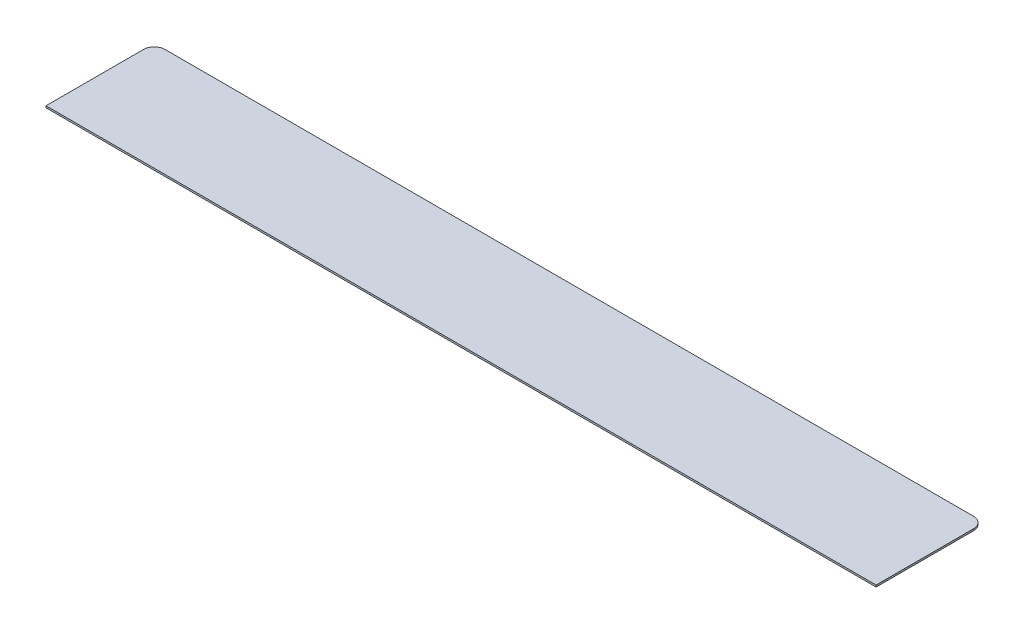
from build123d import *

# Parameters (mm, degrees)
SKETCH1_W           = 230
SKETCH1_H           = 30
BOSS_EXTRUDE1_DEPTH = 0.5
FILLET1_R           = 3


with BuildPart() as part:
    # Sketch1 → Boss-Extrude1 (new body)
    with BuildSketch(Plane(origin=(0, 0, 0), x_dir=(1, 0, 0), z_dir=(0, 1, 0))):
        Rectangle(SKETCH1_W, SKETCH1_H)
    extrude(amount=BOSS_EXTRUDE1_DEPTH)

    # Fillet1
    fillet1_edges = [part.edges().sort_by_distance(p)[0] for p in [
        (-115, 0.25, -15),
        (115, 0.25, -15),
    ]]
    fillet(fillet1_edges, radius=FILLET1_R)


solid = part.part
